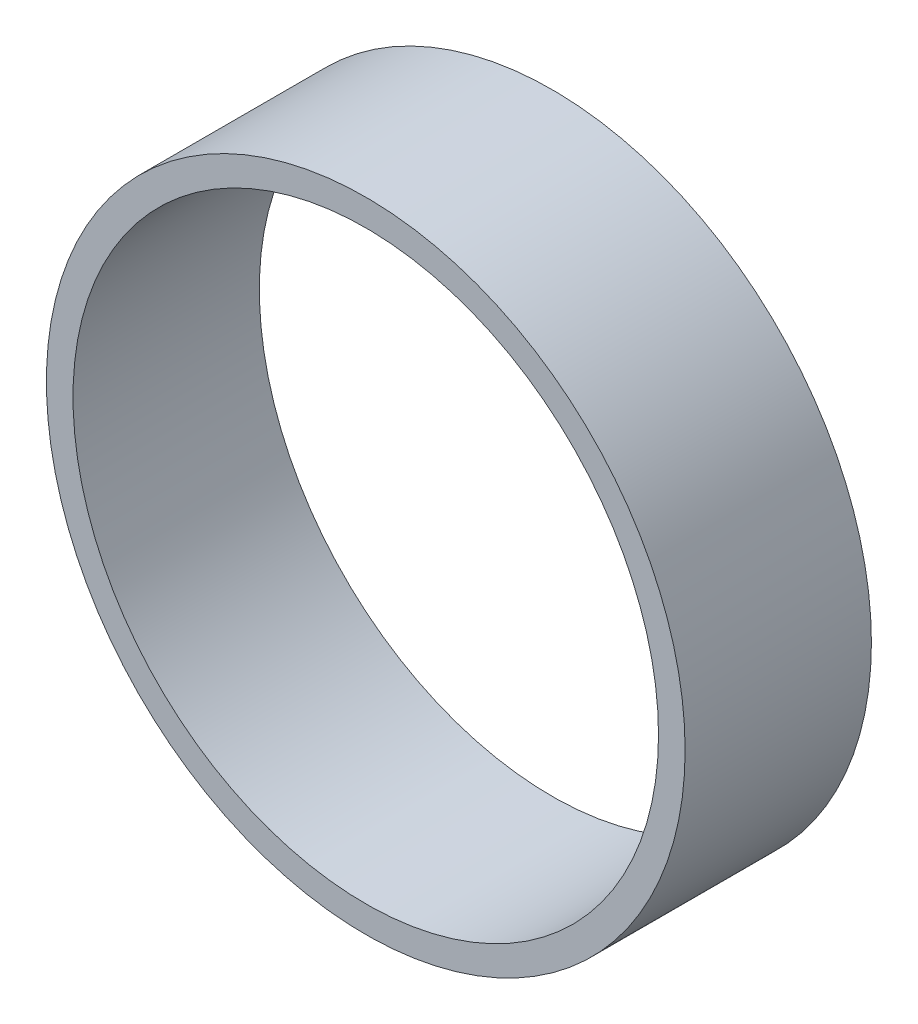
from build123d import *

# Parameters (mm, degrees)
SKETCH2_R      = 76.2
SKETCH2_R_2    = 69.85
EXTRUDE1_DEPTH = 44.45


with BuildPart() as part:
    # Sketch2 → Extrude1 (new body)
    with BuildSketch(Plane.XY.offset(373.3022368)):
        Circle(SKETCH2_R)
        Circle(SKETCH2_R_2, mode=Mode.SUBTRACT)
    extrude(amount=-EXTRUDE1_DEPTH)


solid = part.part
